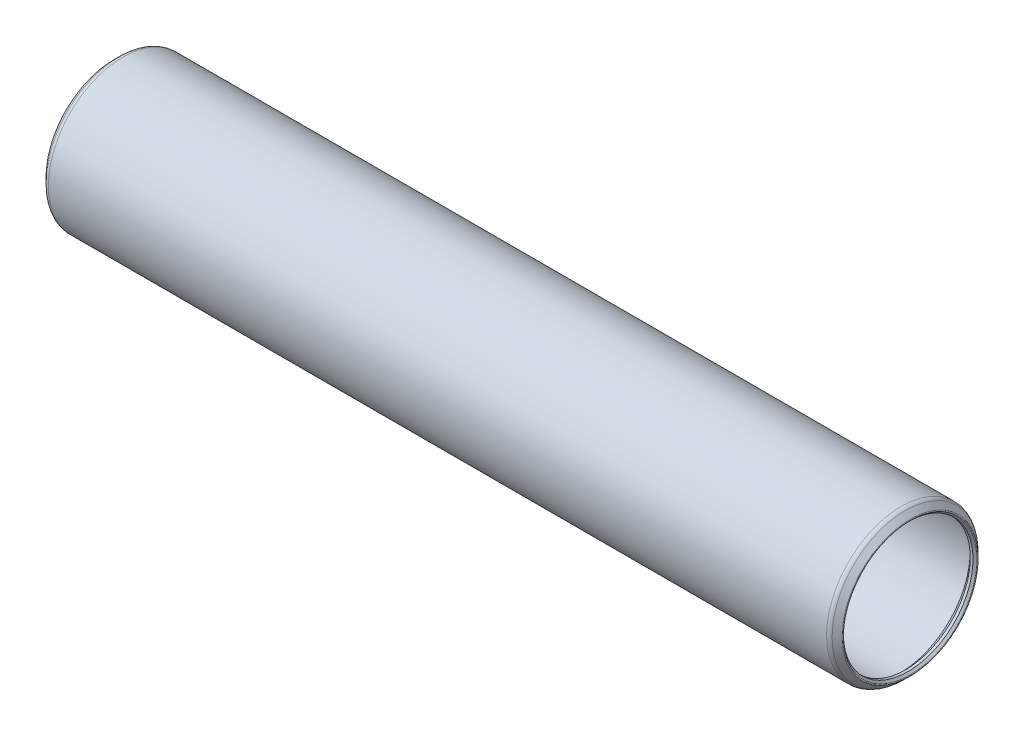
from build123d import *


with BuildPart() as part:
    # Sketch1 → Revolve1 (revolve)
    with BuildSketch(Plane.XY):
        with BuildLine():
            Line((-0.639512806, 9.167562806), (-0.381, 8.90905))
            Line((-0.381, 8.90905), (0, 8.90905))
            Line((0, 8.90905), (0.762, 9.67105))
            Line((0.762, 9.67105), (107.3277, 9.67105))
            Line((107.3277, 9.67105), (108.0897, 8.90905))
            Line((108.0897, 8.90905), (108.4707, 8.90905))
            Line((108.4707, 8.90905), (108.729212806, 9.167562806))
            ThreePointArc((108.729212806, 9.167562806), (108.766410245, 9.257365367), (108.729212806, 9.347167928))
            Line((108.729212806, 9.347167928), (108.044315367, 10.032065367))
            ThreePointArc((108.044315367, 10.032065367), (107.797104775, 10.197246204), (107.5055, 10.25525))
            Line((107.5055, 10.25525), (0.5842, 10.25525))
            ThreePointArc((0.5842, 10.25525), (0.292595225, 10.197246204), (0.045384633, 10.032065367))
            Line((0.045384633, 10.032065367), (-0.639512806, 9.347167928))
            ThreePointArc((-0.639512806, 9.347167928), (-0.676710245, 9.257365367), (-0.639512806, 9.167562806))
        make_face()
    revolve(axis=Axis((108.0897, 0, 0), (-1, 0, 0)))


solid = part.part
